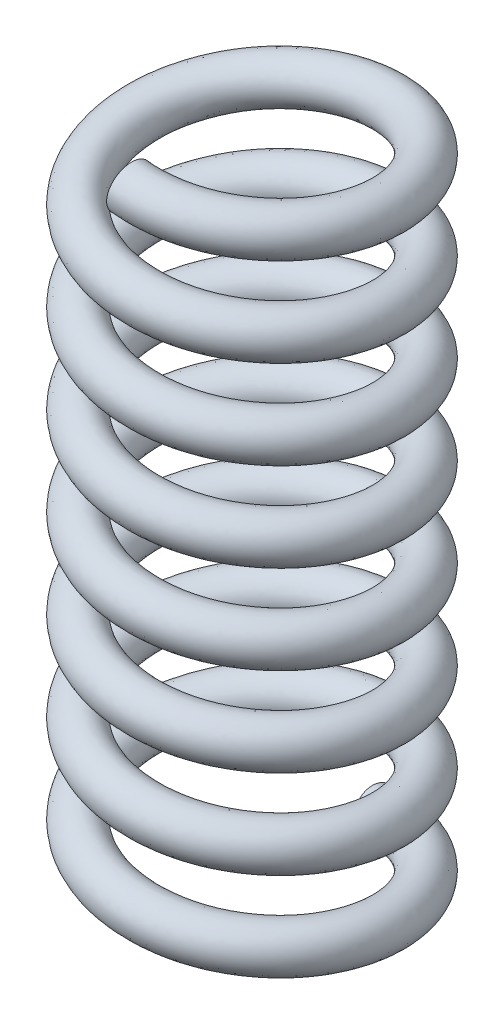
from build123d import *

# Parameters (mm, degrees)
SWEEP1_PITCH       = 2
SWEEP1_HEIGHT      = 15
SWEEP1_RADIUS      = 2.75
SWEEP1_START_ANGLE = -180
SKETCH4_R          = 0.5


with BuildPart() as part:
    # Sweep1: sweep along a helix
    with BuildLine() as sweep1_path:
        add(Helix(SWEEP1_PITCH, SWEEP1_HEIGHT, SWEEP1_RADIUS, center=(0, 0, 0), direction=(0, 1, 0), lefthand=True, mode=Mode.PRIVATE).rotate(Axis((0, 0, 0), (0, 1, 0)), SWEEP1_START_ANGLE))
    # Sketch4 → Sweep1 (sweep)
    with BuildSketch(Plane(origin=(0, 0, -2.75), x_dir=(-0.026096414, 0.225456829, 0.973903586), z_dir=(0.993367649, 0.114981361, 0))):
        with Locations((-0.024708037, 0)):
            Circle(SKETCH4_R)
    sweep(path=sweep1_path.line, is_frenet=True)


solid = part.part
